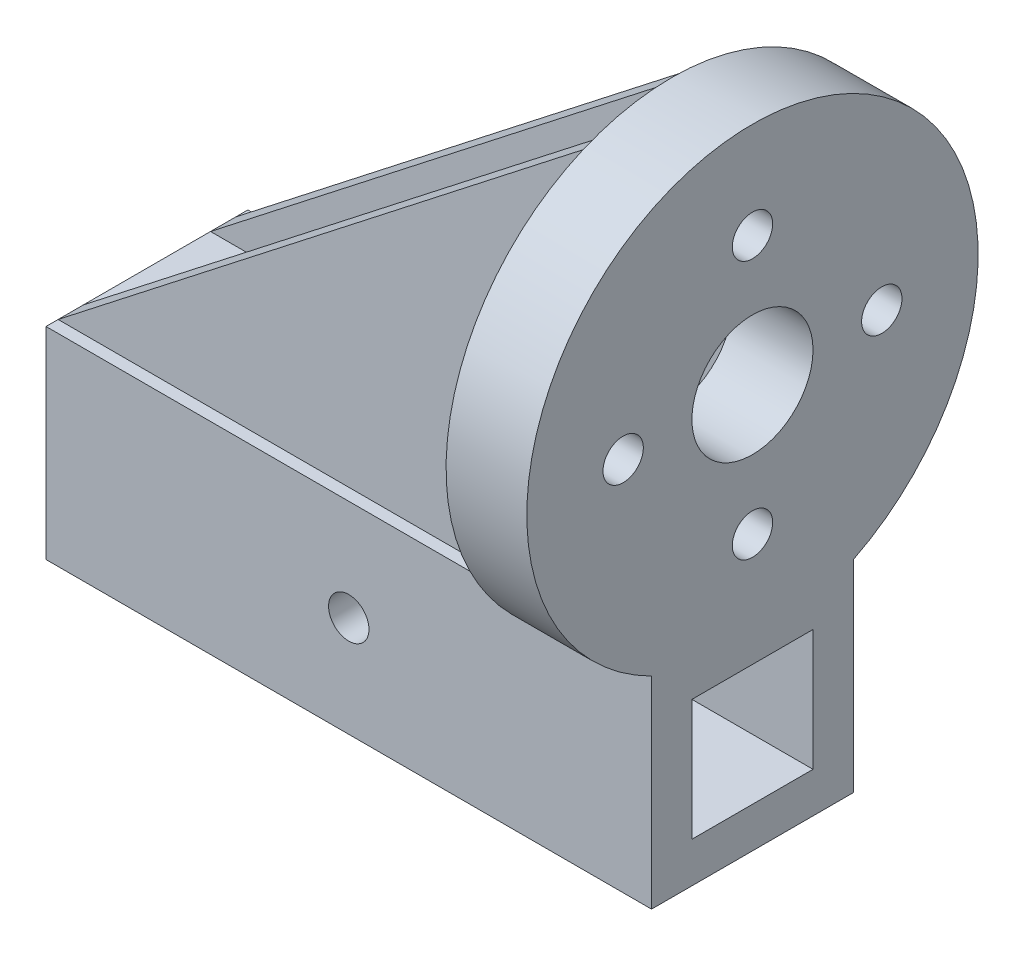
from build123d import *

# Parameters (mm, degrees)
SKETCH2_W               = 150
SKETCH2_H               = 50
BOSS_EXTRUDE1_DEPTH     = 50
SKETCH5_W               = 30
SKETCH5_H               = 30
CUT_EXTRUDE1_DEPTH      = 1
CUT_EXTRUDE1_DEPTH_BACK = 151
SKETCH7_R               = 55.901699437
SKETCH7_R_2             = 15
SKETCH7_R_3             = 5
BOSS_EXTRUDE2_DEPTH     = 20
BOSS_EXTRUDE3_START     = -3
BOSS_EXTRUDE3_DEPTH     = 6.25
SKETCH11_R              = 5
CUT_EXTRUDE2_DEPTH      = 31.901699437
CUT_EXTRUDE2_DEPTH_BACK = 81.901699437


with BuildPart() as part:
    # Sketch2 → Boss-Extrude1 (new body)
    with BuildSketch(Plane(origin=(0, 0, 0), x_dir=(1, 0, 0), z_dir=(0, 1, 0))):
        Rectangle(SKETCH2_W, SKETCH2_H)
    extrude(amount=BOSS_EXTRUDE1_DEPTH)

    # Sketch5 → Cut-Extrude1 (cut, two sides)
    with BuildSketch(Plane(origin=(75, 0, 0), x_dir=(0, 0, -1), z_dir=(1, 0, 0))) as cut_extrude1_sk:
        with Locations((0, 25)):
            Rectangle(SKETCH5_W, SKETCH5_H)
    extrude(amount=CUT_EXTRUDE1_DEPTH, mode=Mode.SUBTRACT)
    extrude(cut_extrude1_sk.sketch, amount=-CUT_EXTRUDE1_DEPTH_BACK, mode=Mode.SUBTRACT)

    # Sketch7 → Boss-Extrude2 (add)
    with BuildSketch(Plane(origin=(75, 0, 0), x_dir=(0, 0, -1), z_dir=(1, 0, 0))):
        with Locations((0, 100)):
            Circle(SKETCH7_R)
        with Locations((0, 100)):
            Circle(SKETCH7_R_2, mode=Mode.SUBTRACT)
        with Locations((0, 132.030384042)):
            Circle(SKETCH7_R_3, mode=Mode.SUBTRACT)
        with Locations((32.030384042, 100)):
            Circle(SKETCH7_R_3, mode=Mode.SUBTRACT)
        with Locations((0, 67.969615958)):
            Circle(SKETCH7_R_3, mode=Mode.SUBTRACT)
        with Locations((-32.030384042, 100)):
            Circle(SKETCH7_R_3, mode=Mode.SUBTRACT)
    extrude(amount=-BOSS_EXTRUDE2_DEPTH)

    # Sketch8 → Boss-Extrude3 (add)
    with BuildSketch(Plane(origin=(0, 0, -25), x_dir=(-1, 0, 0), z_dir=(0, 0, -1)).offset(BOSS_EXTRUDE3_START)):
        Polygon((75, 50), (-55, 151.408233922), (-55, 50), align=None)
    boss_extrude3 = extrude(amount=-BOSS_EXTRUDE3_DEPTH)

    # Sketch11 → Cut-Extrude2 (cut, two sides)
    with BuildSketch(Plane.XY.offset(25)) as cut_extrude2_sk:
        with Locations((0, 25)):
            Circle(SKETCH11_R)
    extrude(amount=CUT_EXTRUDE2_DEPTH, mode=Mode.SUBTRACT)
    extrude(cut_extrude2_sk.sketch, amount=-CUT_EXTRUDE2_DEPTH_BACK, mode=Mode.SUBTRACT)

    # Mirror1: Boss-Extrude3 across plane
    add(boss_extrude3.mirror(Plane.XY))


solid = part.part
